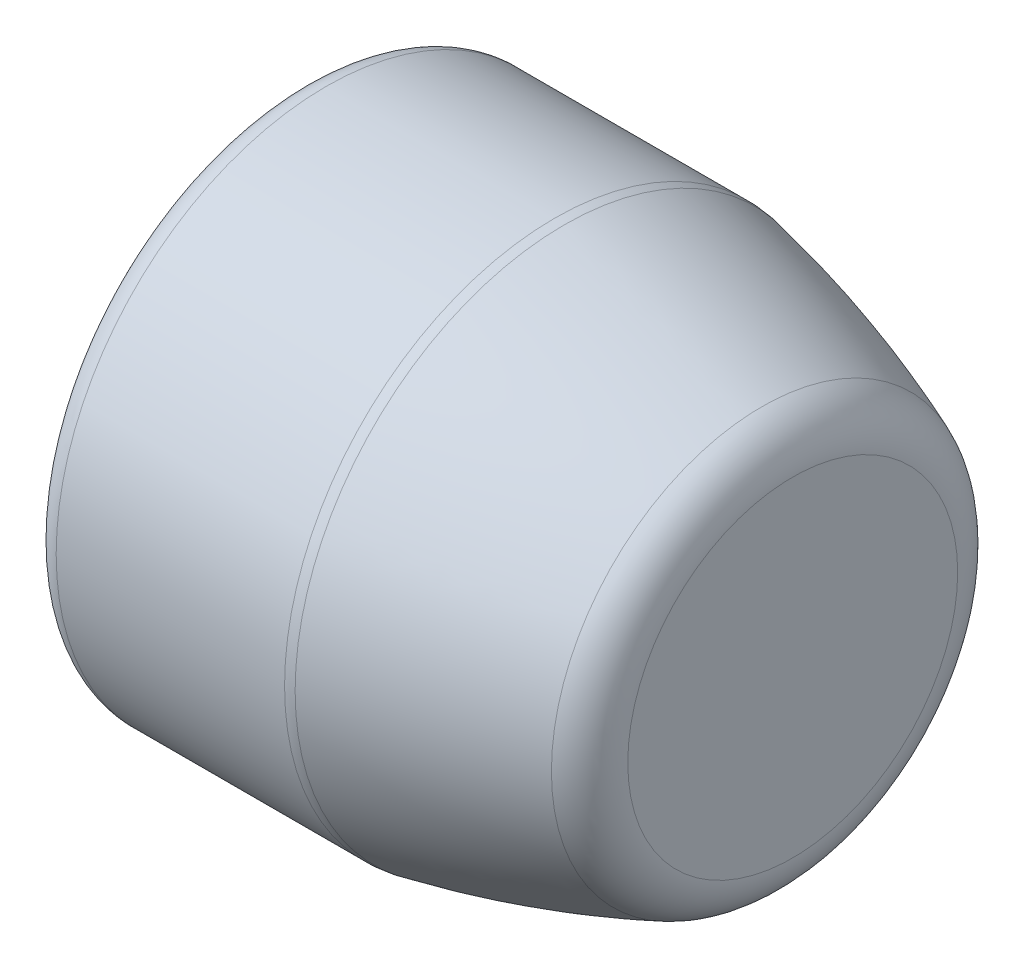
from build123d import *

# Parameters (mm, degrees)
SKETCH1_R           = 1.1
BOSS_EXTRUDE1_DEPTH = 2.5
FILLET1_R           = 0.1
FILLET2_R           = 0.2
SKETCH3_W           = 0.5
SKETCH3_H           = 1.1
FILLET3_R           = 0.1


with BuildPart() as part:
    # Sketch1 → Boss-Extrude1 (new body)
    with BuildSketch(Plane(origin=(0, 0, 0), x_dir=(0, 0, -1), z_dir=(1, 0, 0))):
        Circle(SKETCH1_R)
    extrude(amount=BOSS_EXTRUDE1_DEPTH)

    # Fillet1
    fillet1_edges = [part.edges().sort_by_distance(p)[0] for p in [
        (0, 0, 1.1),
        (2.5, 0, 1.1),
    ]]
    fillet(fillet1_edges, radius=FILLET1_R)

    # Sketch2 → Cut-Revolve2 (revolve, cut)
    with BuildSketch(Plane.XY):
        with BuildLine():
            Line((1.549806351, 1.1), (2.5, 1.1))
            Line((2.5, 1.1), (2.5, 0.804782817))
            add(Edge.make_bspline(
                [(1.549806351, 1.1), (2.048899833, 1.002501981), (2.5, 0.804782817)],
                knots=[0, 0, 0, 0.445191619, 0.445191619, 0.445191619], degree=2))
        make_face()
    revolve(axis=Axis((1.549806351, 0, 0), (1, 0, 0)), mode=Mode.SUBTRACT)

    # Fillet2
    fillet2_edges = [part.edges().sort_by_distance(p)[0] for p in [
        (1.549806351, -0.777817459, 0.777817459),
        (2.5, -0.804782817, 0),
    ]]
    fillet(fillet2_edges, radius=FILLET2_R)

    # Sketch3 → Cut-Revolve3 (revolve, cut)
    with BuildSketch(Plane.XY):
        with Locations((0.25, 0.55)):
            Rectangle(SKETCH3_W, SKETCH3_H)
    revolve(axis=Axis((0.5, 0, 0), (-1, 0, 0)), mode=Mode.SUBTRACT)

    # Fillet3
    fillet3_edges = [part.edges().sort_by_distance(p)[0] for p in [
        (0.5, 0, 1.1),
    ]]
    fillet(fillet3_edges, radius=FILLET3_R)


solid = part.part
